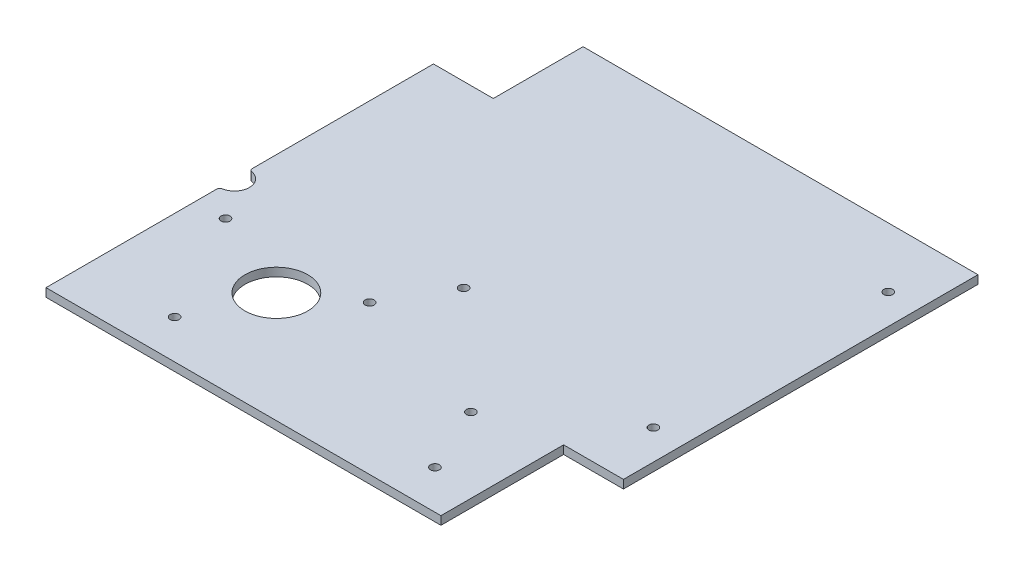
from build123d import *

# Parameters (mm, degrees)
SKETCH1_R           = 1.5
BOSS_EXTRUDE1_DEPTH = 2.8
CUT_EXTRUDE1_REACH  = 4.8
SKETCH2_R           = 1.5
CUT_EXTRUDE2_REACH  = 4.8
SKETCH3_R           = 10.5
CUT_EXTRUDE3_REACH  = 4.8
SKETCH4_R           = 5
FILLET1_R           = 1


with BuildPart() as part:
    # Sketch1 → Boss-Extrude1 (new body)
    with BuildSketch(Plane(origin=(0, 0, 0), x_dir=(1, 0, 0), z_dir=(0, 1, 0))):
        Polygon((-76, -79.75), (56, -79.75), (56, -38.75), (76, -38.75), (76, 79.75), (-56, 79.75), (-56, 49.75), (-76, 49.75), align=None)
        with Locations((-46, -66.75)):
            Circle(SKETCH1_R, mode=Mode.SUBTRACT)
        with Locations((-66, -29.75)):
            Circle(SKETCH1_R, mode=Mode.SUBTRACT)
        with Locations((41, -66.75)):
            Circle(SKETCH1_R, mode=Mode.SUBTRACT)
        with Locations((66, -18.75)):
            Circle(SKETCH1_R, mode=Mode.SUBTRACT)
        with Locations((66, 59.75)):
            Circle(SKETCH1_R, mode=Mode.SUBTRACT)
    extrude(amount=BOSS_EXTRUDE1_DEPTH)

    # Sketch2 → Cut-Extrude1 (cut, up to next)
    with BuildSketch(Plane(origin=(0, 2.8, 0), x_dir=(1, 0, 0), z_dir=(0, 1, 0)), mode=Mode.PRIVATE) as cut_extrude1_sk1:
        with Locations((31, -44.75)):
            Circle(SKETCH2_R)
    cut_extrude1_tool1 = extrude(cut_extrude1_sk1.sketch, amount=-CUT_EXTRUDE1_REACH, mode=Mode.PRIVATE) & part.part
    add(cut_extrude1_tool1.solids().sort_by_distance((31, 2.8, 44.75))[0], mode=Mode.SUBTRACT)
    # Sketch2 → Cut-Extrude1 (cut, up to next)
    with BuildSketch(Plane(origin=(0, 2.8, 0), x_dir=(1, 0, 0), z_dir=(0, 1, 0)), mode=Mode.PRIVATE) as cut_extrude1_sk2:
        with Locations((-6.118257487, -10.040707856)):
            Circle(SKETCH2_R)
    cut_extrude1_tool2 = extrude(cut_extrude1_sk2.sketch, amount=-CUT_EXTRUDE1_REACH, mode=Mode.PRIVATE) & part.part
    add(cut_extrude1_tool2.solids().sort_by_distance((-6.118257, 2.8, 10.040708))[0], mode=Mode.SUBTRACT)
    # Sketch2 → Cut-Extrude1 (cut, up to next)
    with BuildSketch(Plane(origin=(0, 2.8, 0), x_dir=(1, 0, 0), z_dir=(0, 1, 0)), mode=Mode.PRIVATE) as cut_extrude1_sk3:
        with Locations((-17.618257487, -29.959292144)):
            Circle(SKETCH2_R)
    cut_extrude1_tool3 = extrude(cut_extrude1_sk3.sketch, amount=-CUT_EXTRUDE1_REACH, mode=Mode.PRIVATE) & part.part
    add(cut_extrude1_tool3.solids().sort_by_distance((-17.618257, 2.8, 29.959292))[0], mode=Mode.SUBTRACT)

    # Sketch3 → Cut-Extrude2 (cut, up to next)
    with BuildSketch(Plane(origin=(0, 2.8, 0), x_dir=(1, 0, 0), z_dir=(0, 1, 0)), mode=Mode.PRIVATE) as cut_extrude2_sk1:
        with Locations((-36, -42.75)):
            Circle(SKETCH3_R)
    cut_extrude2_tool1 = extrude(cut_extrude2_sk1.sketch, amount=-CUT_EXTRUDE2_REACH, mode=Mode.PRIVATE) & part.part
    add(cut_extrude2_tool1.solids().sort_by_distance((-36, 2.8, 42.75))[0], mode=Mode.SUBTRACT)

    # Sketch4 → Cut-Extrude3 (cut, up to next)
    with BuildSketch(Plane(origin=(0, 2.8, 0), x_dir=(1, 0, 0), z_dir=(0, 1, 0)), mode=Mode.PRIVATE) as cut_extrude3_sk1:
        with Locations((-76, -16.75)):
            Circle(SKETCH4_R)
    cut_extrude3_tool1 = extrude(cut_extrude3_sk1.sketch, amount=-CUT_EXTRUDE3_REACH, mode=Mode.PRIVATE) & part.part
    add(cut_extrude3_tool1.solids().sort_by_distance((-76, 2.8, 16.75))[0], mode=Mode.SUBTRACT)

    # Fillet1
    fillet1_edges = [part.edges().sort_by_distance(p)[0] for p in [
        (-76, 1.4, 21.75),
        (-76, 1.4, 11.75),
    ]]
    fillet(fillet1_edges, radius=FILLET1_R)


solid = part.part
